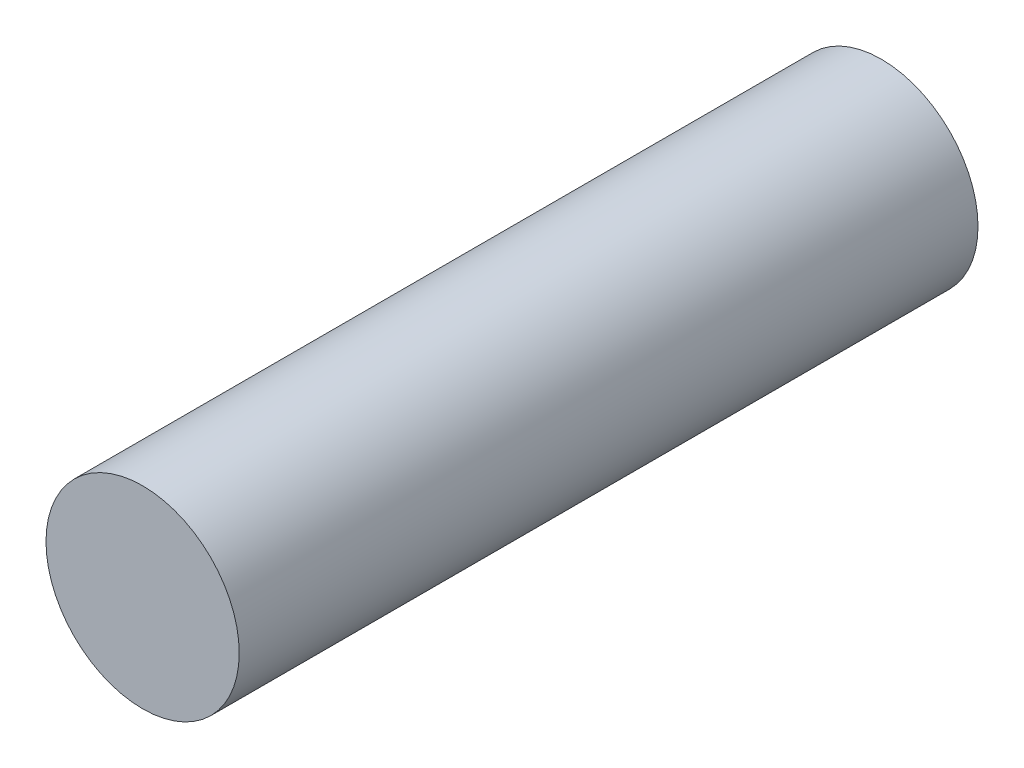
from build123d import *

# Parameters (mm, degrees)
SKETCH1_R           = 8.5
BOSS_EXTRUDE1_DEPTH = 65


with BuildPart() as part:
    # Sketch1 → Boss-Extrude1 (new body)
    with BuildSketch(Plane.XY):
        Circle(SKETCH1_R)
    extrude(amount=BOSS_EXTRUDE1_DEPTH)


solid = part.part
